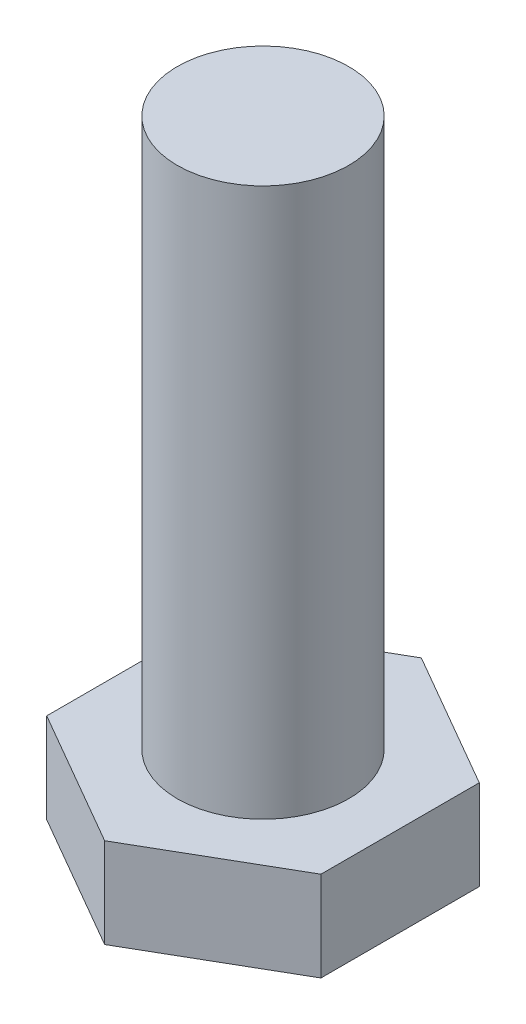
from build123d import *

# Parameters (mm, degrees)
EXTRUDE_1_DEPTH = 3.2
SKETCH_2_R      = 2.5
EXTRUDE_2_DEPTH = 16
CHAMFER_1_SIZE  = 1
CHAMFER_1_SIZE2 = 0.577350269


with BuildPart() as part:
    # Эскиз1 → Бобышка-Вытянуть1 (new body)
    with BuildSketch(Plane(origin=(0, 0, 0), x_dir=(1, 0, 0), z_dir=(0, 1, 0))):
        Polygon((4, -2.309401077), (4, 2.309401077), (0, 4.618802154), (-4, 2.309401077), (-4, -2.309401077), (0, -4.618802154), align=None)
    extrude(amount=EXTRUDE_1_DEPTH)

    # Эскиз2 → Бобышка-Вытянуть2 (add)
    with BuildSketch(Plane(origin=(0, 3.2, 0), x_dir=(1, 0, 0), z_dir=(0, 1, 0))):
        Circle(SKETCH_2_R)
    extrude(amount=EXTRUDE_2_DEPTH)

    # Фаска1
    chamfer_1_edges = [part.edges().sort_by_distance(p)[0] for p in [
        (-2, 0, 3.464101615),
        (-4, 0, 0),
        (-2, 0, -3.464101615),
        (2, 0, -3.464101615),
        (4, 0, 0),
        (2, 0, 3.464101615),
    ]]
    chamfer_1_side = [part.faces().sort_by_distance(p)[0] for p in [
        (0, 0, 0),
    ]]
    chamfer(chamfer_1_edges, length=CHAMFER_1_SIZE, length2=CHAMFER_1_SIZE2, reference=chamfer_1_side[0])


solid = part.part
